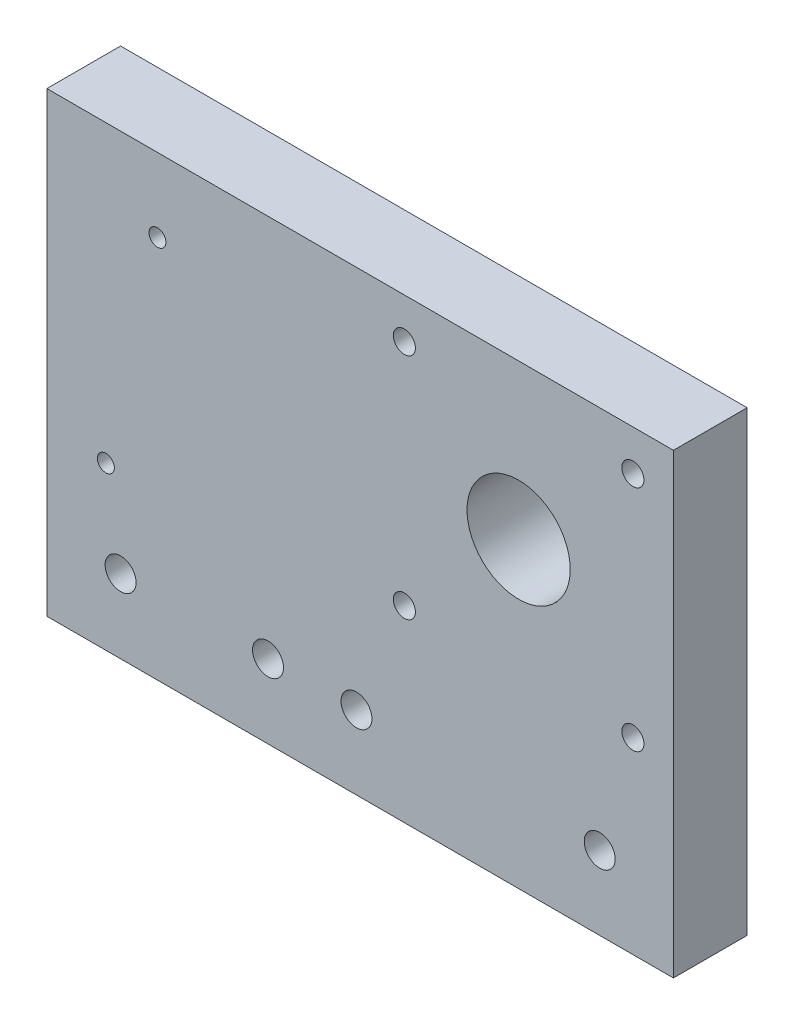
from build123d import *

# Parameters (mm, degrees)
SKETCH1_W           = 85
SKETCH1_H           = 62
SKETCH1_R           = 1.15
SKETCH1_R_2         = 2.1
SKETCH1_R_3         = 7
SKETCH1_R_4         = 1.5
BOSS_EXTRUDE1_DEPTH = 10


with BuildPart() as part:
    # Sketch1 → Boss-Extrude1 (new body)
    with BuildSketch(Plane.XY):
        with Locations((42.5, 31)):
            Rectangle(SKETCH1_W, SKETCH1_H)
        with Locations((8, 22)):
            Circle(SKETCH1_R, mode=Mode.SUBTRACT)
        with Locations((15, 52)):
            Circle(SKETCH1_R, mode=Mode.SUBTRACT)
        with Locations((10, 10)):
            Circle(SKETCH1_R_2, mode=Mode.SUBTRACT)
        with Locations((30, 10)):
            Circle(SKETCH1_R_2, mode=Mode.SUBTRACT)
        with Locations((42, 10)):
            Circle(SKETCH1_R_2, mode=Mode.SUBTRACT)
        with Locations((75, 10)):
            Circle(SKETCH1_R_2, mode=Mode.SUBTRACT)
        with Locations((64, 41)):
            Circle(SKETCH1_R_3, mode=Mode.SUBTRACT)
        with Locations((48.5, 56.5)):
            Circle(SKETCH1_R_4, mode=Mode.SUBTRACT)
        with Locations((79.5, 56.5)):
            Circle(SKETCH1_R_4, mode=Mode.SUBTRACT)
        with Locations((79.5, 25.5)):
            Circle(SKETCH1_R_4, mode=Mode.SUBTRACT)
        with Locations((48.5, 25.5)):
            Circle(SKETCH1_R_4, mode=Mode.SUBTRACT)
    extrude(amount=BOSS_EXTRUDE1_DEPTH)


solid = part.part
